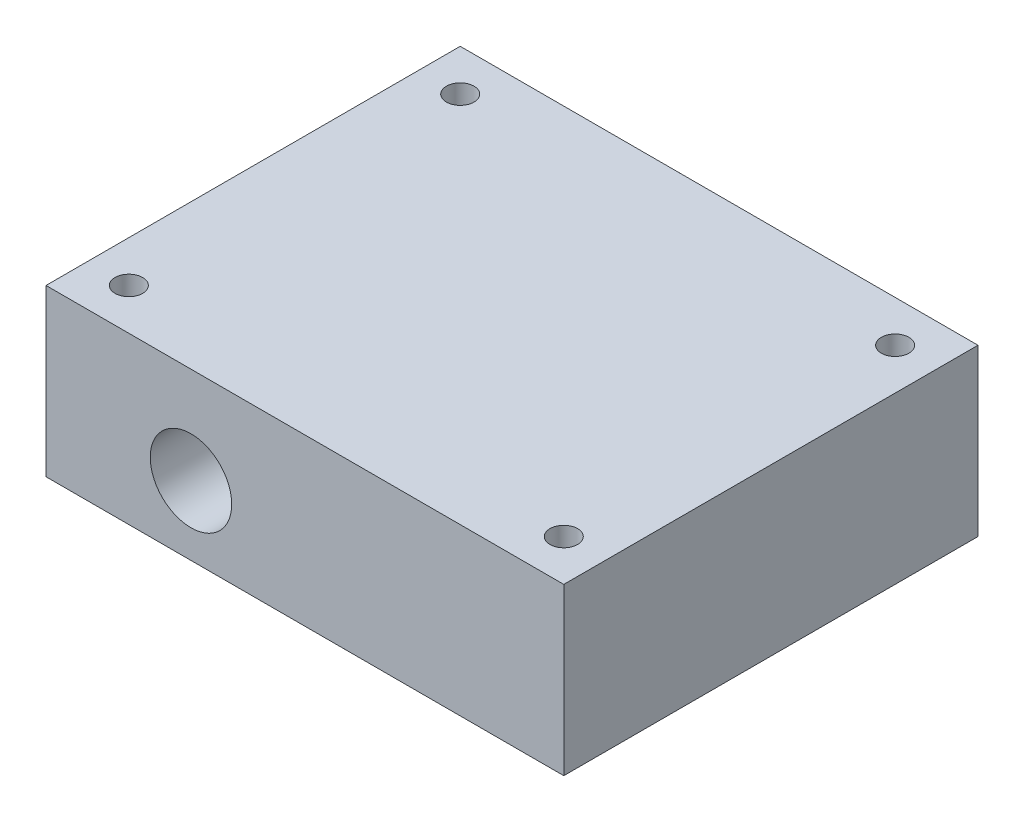
from build123d import *

# Parameters (mm, degrees)
SKETCH1_W           = 75
SKETCH1_H           = 60
BOSS_EXTRUDE1_DEPTH = 24
SKETCH2_R           = 2
CUT_EXTRUDE1_DEPTH  = 25
SKETCH3_W           = 45
SKETCH3_H           = 40
CUT_EXTRUDE2_DEPTH  = 15
SKETCH4_R           = 5
CUT_EXTRUDE3_DEPTH  = 11
SKETCH5_R           = 5.9
CUT_EXTRUDE4_DEPTH  = 10


with BuildPart() as part:
    # Sketch1 → Boss-Extrude1 (new body)
    with BuildSketch(Plane(origin=(0, 0, 0), x_dir=(1, 0, 0), z_dir=(0, 1, 0))):
        with Locations((37.5, 30)):
            Rectangle(SKETCH1_W, SKETCH1_H)
    extrude(amount=BOSS_EXTRUDE1_DEPTH)

    # Sketch2 → Cut-Extrude1 (cut, through all)
    with BuildSketch(Plane(origin=(0, 24, 0), x_dir=(1, 0, 0), z_dir=(0, 1, 0))):
        with Locations((6, 54)):
            Circle(SKETCH2_R)
        with Locations((6, 6)):
            Circle(SKETCH2_R)
        with Locations((69, 54)):
            Circle(SKETCH2_R)
        with Locations((69, 6)):
            Circle(SKETCH2_R)
    extrude(amount=-CUT_EXTRUDE1_DEPTH, mode=Mode.SUBTRACT)

    # Sketch3 → Cut-Extrude2 (cut)
    with BuildSketch(Plane.XZ):
        with Locations((37.5, -30)):
            Rectangle(SKETCH3_W, SKETCH3_H)
    extrude(amount=-CUT_EXTRUDE2_DEPTH, mode=Mode.SUBTRACT)

    # Sketch4 → Cut-Extrude3 (cut, through all)
    with BuildSketch(Plane(origin=(0, 0, -10), x_dir=(-1, 0, 0), z_dir=(0, 0, -1))):
        with Locations((-21, 10)):
            Circle(SKETCH4_R)
    extrude(amount=-CUT_EXTRUDE3_DEPTH, mode=Mode.SUBTRACT)

    # Sketch5 → Cut-Extrude4 (cut)
    with BuildSketch(Plane.XY):
        with Locations((21, 10)):
            Circle(SKETCH5_R)
    extrude(amount=-CUT_EXTRUDE4_DEPTH, mode=Mode.SUBTRACT)


solid = part.part
